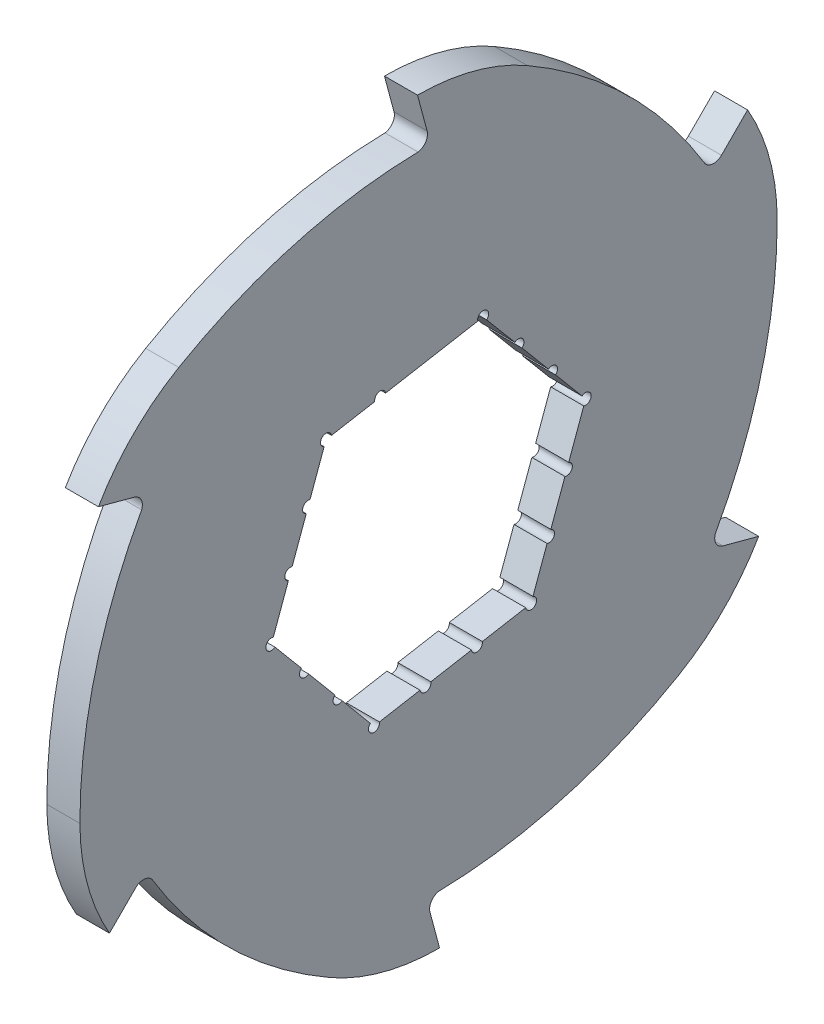
from build123d import *

# Parameters (mm, degrees)
SKETCH1_R                = 59
EXTRUDE1_DEPTH           = 3
EXTRUDE2_DEPTH           = 3
CIRPATTERN1_COUNT        = 6
F_2_0_2_DIAMETER_HOLE1_D = 2
F_2_0_2_DIAMETER_HOLE3_D = 2
F_2_0_2_DIAMETER_HOLE4_D = 2
CIRPATTERN2_COUNT        = 6
CIRPATTERN3_COUNT        = 5
CIRPATTERN3_ANGLE        = 240


with BuildPart() as part:
    # Sketch1 → Extrude1 (new, symmetric)
    with BuildSketch(Plane(origin=(0, 0, 0), x_dir=(0, 0, -1), z_dir=(1, 0, 0))):
        Circle(SKETCH1_R)
        Polygon((28.485808967, 5.022816688), (9.893017633, 27.180842557), (-18.592791334, 22.158025869), (-28.485808967, -5.022816688), (-9.893017633, -27.180842557), (18.592791334, -22.158025869), align=None, mode=Mode.SUBTRACT)
    extrude(amount=EXTRUDE1_DEPTH, both=True)

    # Sketch2 → Extrude2 (add, symmetric)
    with BuildSketch(Plane(origin=(0, 0, 0), x_dir=(0, 0, -1), z_dir=(1, 0, 0))):
        with BuildLine():
            Line((-2, 67.961805723), (-0.262709442, 61.478149092))
            ThreePointArc((-0.262709442, 61.478149092), (-0.58620663, 59.77173183), (-2.122608272, 58.961805723))
            ThreePointArc((-2.122608272, 58.961805723), (28.679663449, 51.560419941), (51.21368579, 29.294340542))
            ThreePointArc((51.21368579, 29.294340542), (36.791707484, 48.186627241), (17.927108603, 62.644803614))
            ThreePointArc((17.927108603, 62.644803614), (8.312130826, 66.609702921), (-2, 67.961805723))
        make_face()
    extrude2 = extrude(amount=EXTRUDE2_DEPTH, both=True)

    # CirPattern1: Extrude2 ×6 about axis
    cirpattern1_axis = Axis((0, 0, 0), (1, 0, 0))
    for i in range(1, CIRPATTERN1_COUNT):
        add(extrude2.rotate(cirpattern1_axis, i * 360 / CIRPATTERN1_COUNT))

    # Ø2.0 (2) Diameter Hole1 (through all)
    with Locations(Plane(origin=(3, 0, 0), x_dir=(0, 0, -1), z_dir=(1, 0, 0))):
        with Locations((9.893017633, 27.180842557), (28.485808967, 5.022816688), (18.592791334, -22.158025869), (-9.893017633, -27.180842557), (-28.485808967, -5.022816688), (-18.592791334, 22.158025869)):
            Hole(F_2_0_2_DIAMETER_HOLE1_D / 2)

    # Ø2.0 (2) Diameter Hole3 (through all)
    with Locations(Plane(origin=(3, 0, 0), x_dir=(0, 0, -1), z_dir=(1, 0, 0))):
        with Locations((16.304877281, 19.539485786)):
            f_2_0_2_diameter_hole3 = Hole(F_2_0_2_DIAMETER_HOLE3_D / 2)

    # Ø2.0 (2) Diameter Hole4 (through all)
    with Locations(Plane(origin=(3, 0, 0), x_dir=(0, 0, -1), z_dir=(1, 0, 0))):
        with Locations((22.395343124, 12.281151237)):
            f_2_0_2_diameter_hole4 = Hole(F_2_0_2_DIAMETER_HOLE4_D / 2)

    # CirPattern2: Ø2.0 (2) Diameter Hole3 ×6 about axis
    cirpattern2_axis = Axis((0, 0, 0), (1, 0, 0))
    for i in range(1, CIRPATTERN2_COUNT):
        add(f_2_0_2_diameter_hole3.rotate(cirpattern2_axis, i * 360 / CIRPATTERN2_COUNT), mode=Mode.SUBTRACT)

    # CirPattern3: Ø2.0 (2) Diameter Hole4 ×5 about axis
    cirpattern3_axis = Axis((0, 0, 0), (-1, 0, 0))
    for i in range(1, CIRPATTERN3_COUNT):
        add(f_2_0_2_diameter_hole4.rotate(cirpattern3_axis, i * CIRPATTERN3_ANGLE / (CIRPATTERN3_COUNT - 1)), mode=Mode.SUBTRACT)


solid = part.part
